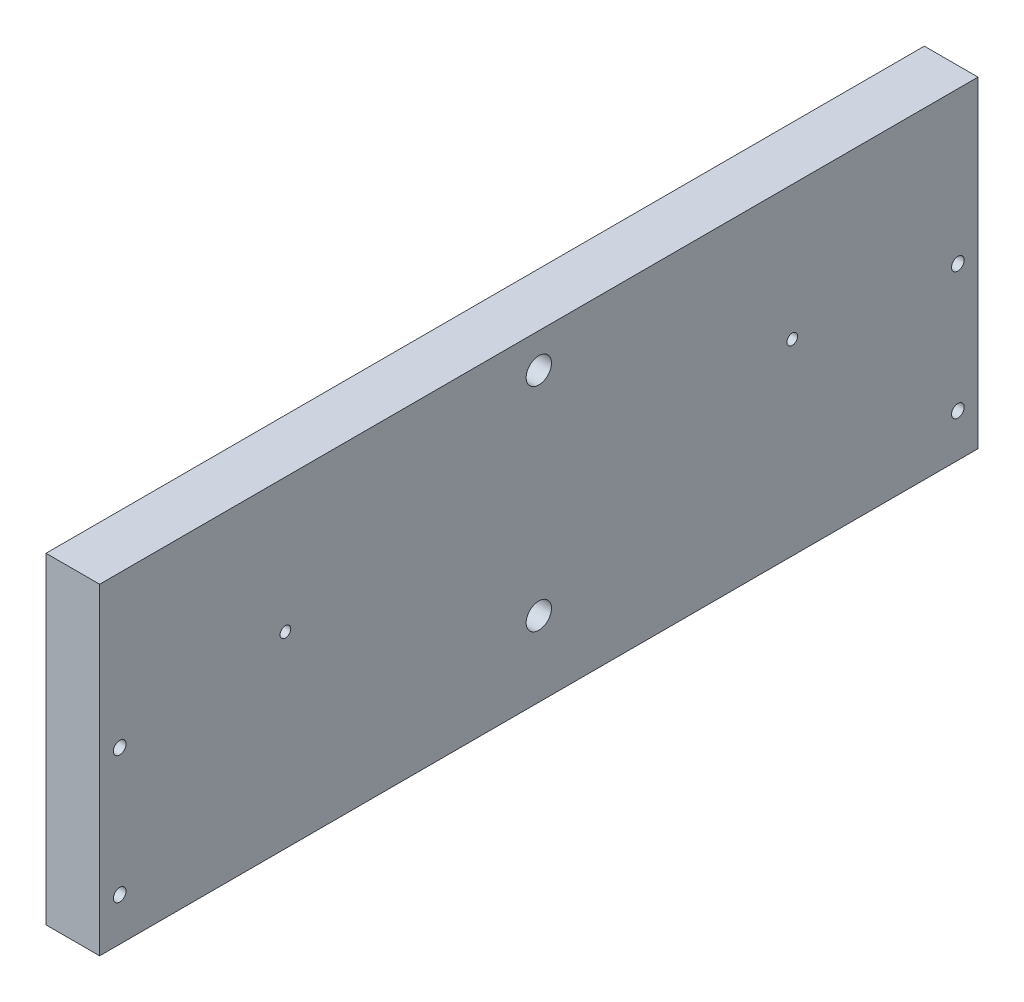
from build123d import *

# Parameters (mm, degrees)
SKETCH1_W           = 207.9625
SKETCH1_H           = 76.2
SKETCH1_R           = 3
SKETCH1_R_2         = 1.27
SKETCH1_R_3         = 1.5
BOSS_EXTRUDE1_DEPTH = 12.7


with BuildPart() as part:
    # Sketch1 → Boss-Extrude1 (new body)
    with BuildSketch(Plane(origin=(0, 0, 0), x_dir=(0, 0, -1), z_dir=(1, 0, 0))):
        with Locations((103.98125, 38.1)):
            Rectangle(SKETCH1_W, SKETCH1_H)
        with Locations((103.98125, 68.072)):
            Circle(SKETCH1_R, mode=Mode.SUBTRACT)
        with Locations((103.98125, 17.78)):
            Circle(SKETCH1_R, mode=Mode.SUBTRACT)
        with Locations((43.981250056, 44.45)):
            Circle(SKETCH1_R_2, mode=Mode.SUBTRACT)
        with Locations((163.981249944, 44.45)):
            Circle(SKETCH1_R_2, mode=Mode.SUBTRACT)
        with Locations((4.7625, 40.3225)):
            Circle(SKETCH1_R_3, mode=Mode.SUBTRACT)
        with Locations((4.7625, 10.16)):
            Circle(SKETCH1_R_3, mode=Mode.SUBTRACT)
        with Locations((203.2, 40.3225)):
            Circle(SKETCH1_R_3, mode=Mode.SUBTRACT)
        with Locations((203.2, 10.16)):
            Circle(SKETCH1_R_3, mode=Mode.SUBTRACT)
    extrude(amount=BOSS_EXTRUDE1_DEPTH)


solid = part.part
